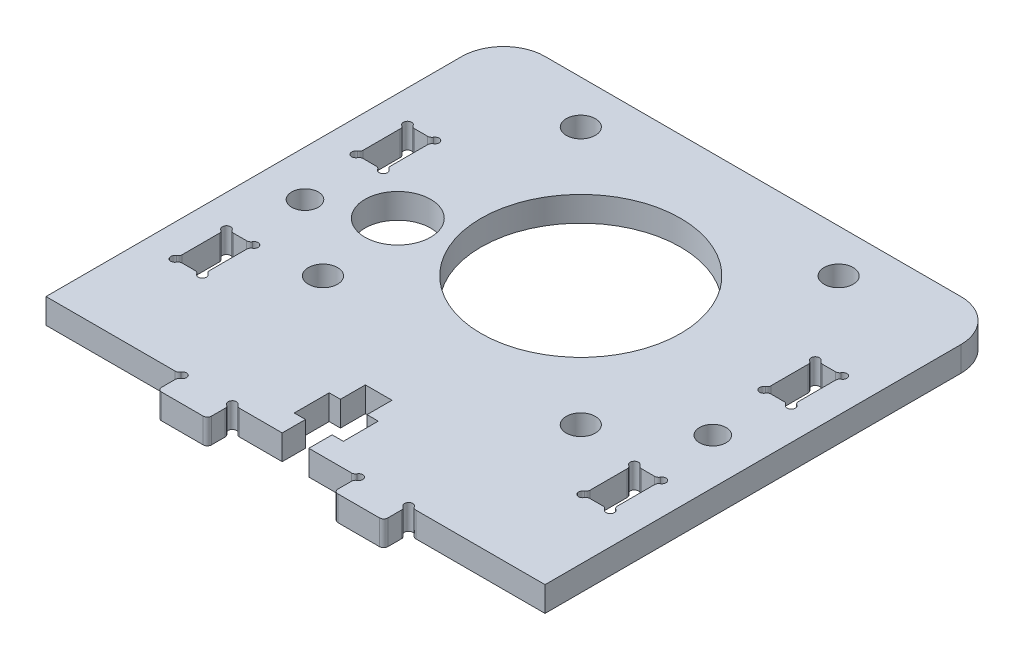
from build123d import *

# Parameters (mm, degrees)
SKETCH1_R           = 1.6
SKETCH1_R_2         = 1.75
SKETCH1_R_3         = 3.95
SKETCH1_R_4         = 12
BOSS_EXTRUDE1_DEPTH = 3


with BuildPart() as part:
    # Sketch1 → Boss-Extrude1 (new body)
    with BuildSketch(Plane(origin=(0, 0, 0), x_dir=(1, 0, 0), z_dir=(0, 1, 0))):
        with BuildLine():
            Line((312.373352996, 1022.190294437), (327.907309833, 1022.190294437))
            ThreePointArc((327.907309833, 1022.190294437), (328.157309833, 1022.257281735), (328.340322535, 1022.440294437))
            ThreePointArc((328.340322535, 1022.440294437), (329.126888323, 1022.543848684), (329.023336329, 1021.757282599))
            ThreePointArc((329.023336329, 1021.757282599), (328.840324865, 1021.574270305), (328.773337833, 1021.324271437))
            Line((328.773337833, 1021.324271437), (328.773337833, 1019.690242437))
            ThreePointArc((328.773337833, 1019.690242437), (328.919784442, 1019.336689047), (329.273337833, 1019.190242437))
            Line((329.273337833, 1019.190242437), (334.273335833, 1019.190242437))
            ThreePointArc((334.273335833, 1019.190242437), (334.626889492, 1019.336688397), (334.773336751, 1019.690241519))
            Line((334.773336751, 1019.690241519), (334.773336751, 1021.324268519))
            ThreePointArc((334.773336751, 1021.324268519), (334.706349307, 1021.57426848), (334.523336498, 1021.757281075))
            ThreePointArc((334.523336498, 1021.757281075), (334.419781792, 1022.543846802), (335.206347937, 1022.440295269))
            ThreePointArc((335.206347937, 1022.440295269), (335.389360338, 1022.257283911), (335.639359245, 1022.190297025))
            Line((335.639359245, 1022.190297025), (340.773337745, 1022.190297025))
            Line((340.773337745, 1022.190297025), (340.773337745, 1024.990297025))
            Line((340.773337745, 1024.990297025), (339.423337745, 1024.990297025))
            Line((339.423337745, 1024.990297025), (339.423337745, 1029.190297025))
            Line((339.423337745, 1029.190297025), (340.773337745, 1029.190297025))
            Line((340.773337745, 1029.190297025), (340.773337745, 1032.190297025))
            Line((340.773337745, 1032.190297025), (343.973337745, 1032.190297025))
            Line((343.973337745, 1032.190297025), (343.973337745, 1029.190297025))
            Line((343.973337745, 1029.190297025), (345.323337745, 1029.190297025))
            Line((345.323337745, 1029.190297025), (345.323337745, 1024.990292188))
            Line((345.323337745, 1024.990292188), (343.973337745, 1024.990292188))
            Line((343.973337745, 1024.990292188), (343.973337745, 1022.190292188))
            Line((343.973337745, 1022.190292188), (349.107314245, 1022.190292188))
            ThreePointArc((349.107314245, 1022.190292188), (349.357314245, 1022.257279486), (349.540326947, 1022.440292188))
            ThreePointArc((349.540326947, 1022.440292188), (350.326891976, 1022.543845827), (350.223341741, 1021.75728035))
            ThreePointArc((350.223341741, 1021.75728035), (350.040330277, 1021.574268055), (349.973343245, 1021.324269188))
            Line((349.973343245, 1021.324269188), (349.973343245, 1019.690240188))
            ThreePointArc((349.973343245, 1019.690240188), (350.119789854, 1019.336686797), (350.473343245, 1019.190240188))
            Line((350.473343245, 1019.190240188), (355.473340245, 1019.190240188))
            ThreePointArc((355.473340245, 1019.190240188), (355.826893904, 1019.336686148), (355.973341163, 1019.69023927))
            Line((355.973341163, 1019.69023927), (355.973341163, 1021.32426627))
            ThreePointArc((355.973341163, 1021.32426627), (355.906353816, 1021.574266257), (355.723341079, 1021.757278924))
            ThreePointArc((355.723341079, 1021.757278924), (355.619786681, 1022.543844692), (356.406352785, 1022.44029285))
            ThreePointArc((356.406352785, 1022.44029285), (356.589365548, 1022.257281171), (356.839364996, 1022.190294437))
            Line((356.839364996, 1022.190294437), (372.373340046, 1022.190294437))
            Line((372.373340046, 1022.190294437), (372.373340046, 1072.190301225))
            ThreePointArc((372.373340046, 1072.190301225), (370.908875012, 1075.72583207), (367.373345046, 1077.190299225))
            Line((367.373345046, 1077.190299225), (317.373348046, 1077.190299225))
            ThreePointArc((317.373348046, 1077.190299225), (313.837816014, 1075.725834155), (312.373352996, 1072.190301275))
            Line((312.373352996, 1072.190301275), (312.373352996, 1022.190294437))
        make_face()
        with Locations((366.893344996, 1047.842461747)):
            Circle(SKETCH1_R, mode=Mode.SUBTRACT)
        with Locations((357.873345496, 1071.990299275)):
            Circle(SKETCH1_R_2, mode=Mode.SUBTRACT)
        with Locations((357.873345496, 1040.990299275)):
            Circle(SKETCH1_R_2, mode=Mode.SUBTRACT)
        with Locations((325.373345996, 1051.490299275)):
            Circle(SKETCH1_R_3, mode=Mode.SUBTRACT)
        with Locations((342.373345496, 1056.490299275)):
            Circle(SKETCH1_R_4, mode=Mode.SUBTRACT)
        with Locations((326.873345496, 1071.990299275)):
            Circle(SKETCH1_R_2, mode=Mode.SUBTRACT)
        with Locations((326.873345496, 1040.990299275)):
            Circle(SKETCH1_R_2, mode=Mode.SUBTRACT)
        with Locations((317.853347996, 1047.84952041)):
            Circle(SKETCH1_R, mode=Mode.SUBTRACT)
        with BuildLine():
            Line((365.243389653, 1060.95296097), (365.243389653, 1056.48501097))
            ThreePointArc((365.243389653, 1056.48501097), (365.176400533, 1056.235010504), (364.993385671, 1056.051998658))
            ThreePointArc((364.993385671, 1056.051998658), (364.889836092, 1055.26543287), (365.676401176, 1055.368987799))
            ThreePointArc((365.676401176, 1055.368987799), (365.859413353, 1055.55200075), (366.109412996, 1055.618988627))
            Line((366.109412996, 1055.618988627), (367.677282996, 1055.618988627))
            ThreePointArc((367.677282996, 1055.618988627), (367.927282247, 1055.552001761), (368.110294834, 1055.368990124))
            ThreePointArc((368.110294834, 1055.368990124), (368.896860423, 1055.26543905), (368.793306996, 1056.052004329))
            ThreePointArc((368.793306996, 1056.052004329), (368.610294145, 1056.235017289), (368.543306996, 1056.485017627))
            Line((368.543306996, 1056.485017627), (368.543306996, 1060.952967627))
            ThreePointArc((368.543306996, 1060.952967627), (368.610293862, 1061.202966879), (368.793305499, 1061.385979465))
            ThreePointArc((368.793305499, 1061.385979465), (368.89685718, 1062.172545813), (368.110291294, 1062.068990627))
            ThreePointArc((368.110291294, 1062.068990627), (367.927278767, 1061.885978026), (367.677278996, 1061.818990627))
            Line((367.677278996, 1061.818990627), (366.109410996, 1061.818990627))
            ThreePointArc((366.109410996, 1061.818990627), (365.859411616, 1061.885977015), (365.676398679, 1062.068988302))
            ThreePointArc((365.676398679, 1062.068988302), (364.889832133, 1062.172538478), (364.993388824, 1061.38597279))
            ThreePointArc((364.993388824, 1061.38597279), (365.176401775, 1061.202960613), (365.243389653, 1060.95296097))
        make_face(mode=Mode.SUBTRACT)
        with BuildLine():
            Line((318.637281496, 1061.818997965), (317.069414496, 1061.818997965))
            ThreePointArc((317.069414496, 1061.818997965), (316.819415116, 1061.885984352), (316.636402179, 1062.06899564))
            ThreePointArc((316.636402179, 1062.06899564), (315.849836392, 1062.172545208), (315.953391324, 1061.385980127))
            ThreePointArc((315.953391324, 1061.385980127), (316.136404615, 1061.202967361), (316.203392153, 1060.952966947))
            Line((316.203392153, 1060.952966947), (316.203392153, 1056.485018307))
            ThreePointArc((316.203392153, 1056.485018307), (316.136403033, 1056.235017841), (315.953388171, 1056.052005995))
            ThreePointArc((315.953388171, 1056.052005995), (315.849838592, 1055.265440207), (316.636403676, 1055.368995136))
            ThreePointArc((316.636403676, 1055.368995136), (316.819416286, 1055.552008337), (317.069416496, 1055.618995965))
            Line((317.069416496, 1055.618995965), (318.637286496, 1055.618995965))
            ThreePointArc((318.637286496, 1055.618995965), (318.887285747, 1055.552009098), (319.070298334, 1055.368997461))
            ThreePointArc((319.070298334, 1055.368997461), (319.856863923, 1055.265446387), (319.753310496, 1056.052011666))
            ThreePointArc((319.753310496, 1056.052011666), (319.570297645, 1056.235024626), (319.503310496, 1056.485024964))
            Line((319.503310496, 1056.485024964), (319.503310496, 1060.952974964))
            ThreePointArc((319.503310496, 1060.952974964), (319.570297362, 1061.202974216), (319.753308999, 1061.385986802))
            ThreePointArc((319.753308999, 1061.385986802), (319.85686068, 1062.17255315), (319.070294794, 1062.068997964))
            ThreePointArc((319.070294794, 1062.068997964), (318.887281834, 1061.885985114), (318.637281496, 1061.818997965))
        make_face(mode=Mode.SUBTRACT)
        with BuildLine():
            Line((316.203388653, 1039.193570463), (316.203388653, 1034.725621463))
            ThreePointArc((316.203388653, 1034.725621463), (316.136399531, 1034.475620993), (315.953384663, 1034.292609147))
            ThreePointArc((315.953384663, 1034.292609147), (315.849835095, 1033.506043359), (316.636400176, 1033.609598291))
            ThreePointArc((316.636400176, 1033.609598291), (316.819412786, 1033.792611493), (317.069412996, 1033.85959912))
            Line((317.069412996, 1033.85959912), (318.637282996, 1033.85959912))
            ThreePointArc((318.637282996, 1033.85959912), (318.887282247, 1033.792612254), (319.070294834, 1033.609600616))
            ThreePointArc((319.070294834, 1033.609600616), (319.856860423, 1033.506049543), (319.753306996, 1034.292614822))
            ThreePointArc((319.753306996, 1034.292614822), (319.570294395, 1034.475627349), (319.503306996, 1034.72562712))
            Line((319.503306996, 1034.72562712), (319.503306996, 1039.19357712))
            ThreePointArc((319.503306996, 1039.19357712), (319.570293862, 1039.443576372), (319.753305499, 1039.626588958))
            ThreePointArc((319.753305499, 1039.626588958), (319.856856573, 1040.413154547), (319.070291294, 1040.30960112))
            ThreePointArc((319.070291294, 1040.30960112), (318.887278334, 1040.126588269), (318.637277996, 1040.05960112))
            Line((318.637277996, 1040.05960112), (317.069410996, 1040.05960112))
            ThreePointArc((317.069410996, 1040.05960112), (316.819411616, 1040.126587508), (316.636398679, 1040.309598795))
            ThreePointArc((316.636398679, 1040.309598795), (315.849832892, 1040.413148364), (315.953387824, 1039.626583283))
            ThreePointArc((315.953387824, 1039.626583283), (316.136401025, 1039.443570673), (316.203388653, 1039.193570463))
        make_face(mode=Mode.SUBTRACT)
        with BuildLine():
            Line((368.543303996, 1034.72562712), (368.543303996, 1039.19357712))
            ThreePointArc((368.543303996, 1039.19357712), (368.610290862, 1039.443576372), (368.793302499, 1039.626588958))
            ThreePointArc((368.793302499, 1039.626588958), (368.896853573, 1040.413154547), (368.110288294, 1040.30960112))
            ThreePointArc((368.110288294, 1040.30960112), (367.927275767, 1040.126588519), (367.677275996, 1040.05960112))
            Line((367.677275996, 1040.05960112), (366.109407996, 1040.05960112))
            ThreePointArc((366.109407996, 1040.05960112), (365.859408616, 1040.126587508), (365.676395679, 1040.309598795))
            ThreePointArc((365.676395679, 1040.309598795), (364.889829133, 1040.413148971), (364.993385824, 1039.626583283))
            ThreePointArc((364.993385824, 1039.626583283), (365.176399025, 1039.443570673), (365.243386653, 1039.193570463))
            Line((365.243386653, 1039.193570463), (365.243386653, 1034.725621463))
            ThreePointArc((365.243386653, 1034.725621463), (365.176397531, 1034.475620993), (364.993382663, 1034.292609147))
            ThreePointArc((364.993382663, 1034.292609147), (364.889833095, 1033.506043359), (365.676398176, 1033.609598291))
            ThreePointArc((365.676398176, 1033.609598291), (365.859410353, 1033.792611243), (366.109409996, 1033.85959912))
            Line((366.109409996, 1033.85959912), (367.677279996, 1033.85959912))
            ThreePointArc((367.677279996, 1033.85959912), (367.927279247, 1033.792612254), (368.110291834, 1033.609600616))
            ThreePointArc((368.110291834, 1033.609600616), (368.896857423, 1033.506049543), (368.793303996, 1034.292614822))
            ThreePointArc((368.793303996, 1034.292614822), (368.610291395, 1034.475627349), (368.543303996, 1034.72562712))
        make_face(mode=Mode.SUBTRACT)
    extrude(amount=BOSS_EXTRUDE1_DEPTH)


solid = part.part
